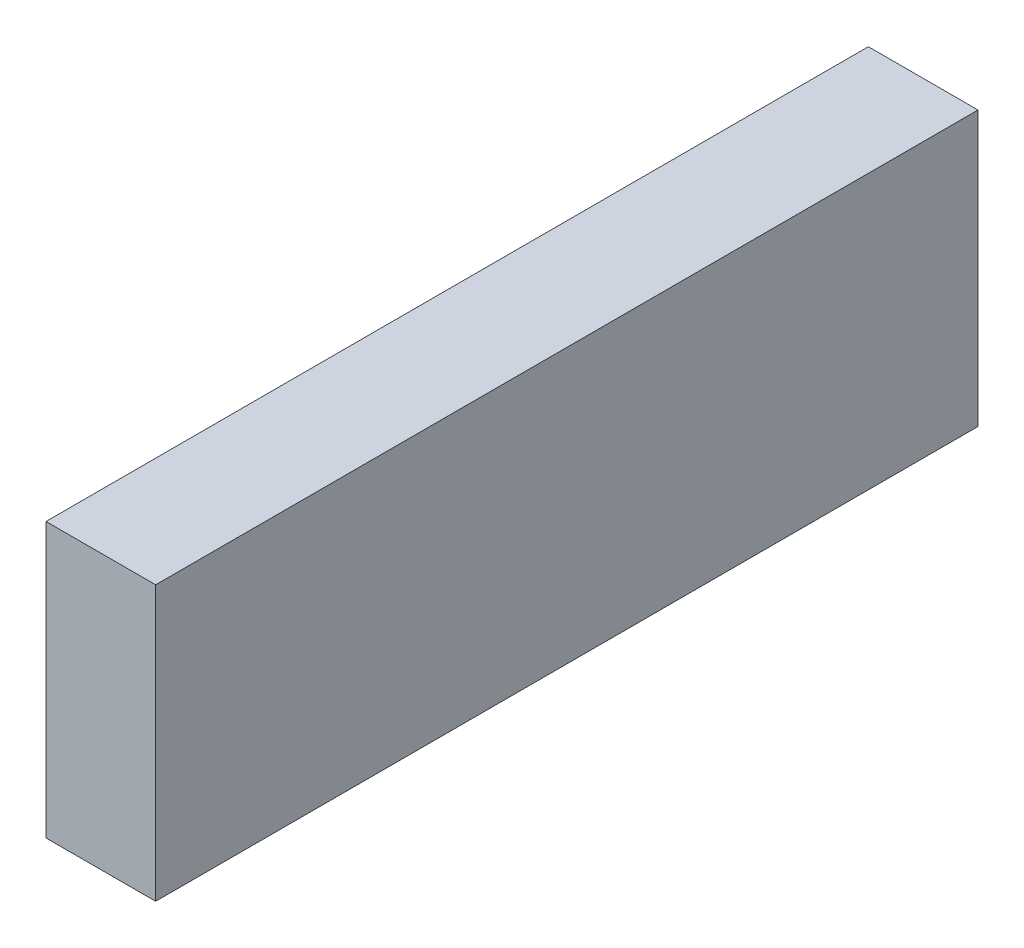
from build123d import *

# Parameters (mm, degrees)
SKETCH1_W           = 300
SKETCH1_H           = 100
BOSS_EXTRUDE1_DEPTH = 40


with BuildPart() as part:
    # Sketch1 → Boss-Extrude1 (new body)
    with BuildSketch(Plane(origin=(0, 0, 0), x_dir=(0, 0, -1), z_dir=(1, 0, 0))):
        Rectangle(SKETCH1_W, SKETCH1_H)
    extrude(amount=BOSS_EXTRUDE1_DEPTH)


solid = part.part
